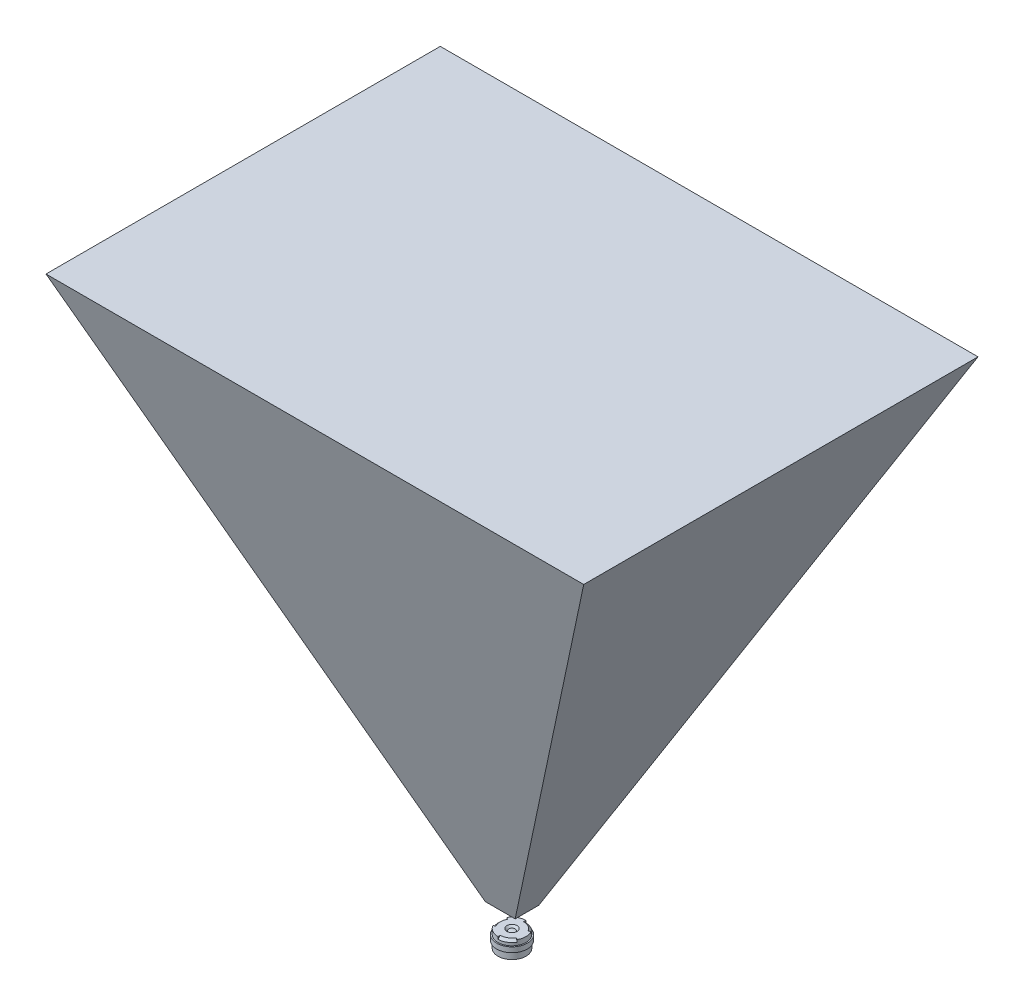
from build123d import *

# Parameters (mm, degrees)
SKIZZE4_W             = 0.25
SKIZZE4_H             = 1
TOOLFACE_ANGLE        = 60
KREISMUSTER1_COUNT    = 3
FOV_3_6MM_F_2_9_DEPTH = 100
SKIZZE8_OUTSIDE_W     = 249.988
SKIZZE8_OUTSIDE_H     = 157.596
SKIZZE8_OUTSIDE_R     = 5
FOV2_DEPTH            = 39.708234414
FOV2_DEPTH_BACK       = 39.708234414


with BuildPart() as part:
    # Skizze3 → Body (revolve)
    with BuildSketch(Plane.XY):
        with BuildLine():
            Line((1, 0.8), (2.75, 0.8))
            Line((2.75, 0.8), (2.75, -2.55))
            Line((2.75, -2.55), (2.1, -2.55))
            Line((2.1, -2.55), (1.8, -2.25))
            ThreePointArc((1.8, -2.25), (0.91241438, -2.474486277), (0, -2.55))
            Line((0, -2.55), (0, 0.525))
            ThreePointArc((0, 0.525), (0.316474723, 0.499842016), (0.625, 0.425))
            Line((0.625, 0.425), (1, 0.8))
        make_face()
    revolve(axis=Axis((0, 0, 0), (0, -1, 0)))

    # Skizze4 → Thread (revolve)
    with BuildSketch(Plane.XY):
        with Locations((2.875, -0.7)):
            Rectangle(SKIZZE4_W, SKIZZE4_H)
    revolve(axis=Axis((0, 0, 0), (0, 1, 0)))

    # Skizze5 → Toolface (revolve, cut)
    with BuildSketch(Plane(origin=(0, 0, 0), x_dir=(0, 0, -1), z_dir=(1, 0, 0))):
        Polygon((2.75, 0.8), (2.75, 0.35), (2.3, 0.8), align=None)
    toolface = revolve(axis=Axis((0, 0, 0), (0, -1, 0)), revolution_arc=TOOLFACE_ANGLE, mode=Mode.SUBTRACT)

    # Kreismuster1: Toolface ×3 about axis
    kreismuster1_axis = Axis((0, 0, 0), (0, 1, 0))
    for i in range(1, KREISMUSTER1_COUNT):
        add(toolface.rotate(kreismuster1_axis, i * 360 / KREISMUSTER1_COUNT), mode=Mode.SUBTRACT)


with BuildPart() as body_2:
    # Skizze6 → FOV - 3,6mm f/2,9 (new body, symmetric)
    with BuildSketch(Plane(origin=(0, 0, 0), x_dir=(0, 0, -1), z_dir=(1, 0, 0))):
        Polygon((-2.311210988, 5.057826613), (-38.708234414, 105.057826613), (38.708234414, 105.057826613), (2.311210988, 5.057826613), align=None)
    extrude(amount=FOV_3_6MM_F_2_9_DEPTH, both=True)

    # Skizze8 outside → FOV2 (cut, two sides)
    with BuildSketch(Plane.XY) as fov2_sk:
        with Locations((0, 51.254)):
            Rectangle(SKIZZE8_OUTSIDE_W, SKIZZE8_OUTSIDE_H)
        Circle(SKIZZE8_OUTSIDE_R, mode=Mode.SUBTRACT)
        Polygon((-2.934842142, 5.057826613), (-52.793002948, 105.057826613), (52.793002948, 105.057826613), (2.934842142, 5.057826613), align=None, mode=Mode.SUBTRACT)
    extrude(amount=FOV2_DEPTH, mode=Mode.SUBTRACT)
    extrude(fov2_sk.sketch, amount=-FOV2_DEPTH_BACK, mode=Mode.SUBTRACT)


solid = Compound([part.part, body_2.part])
